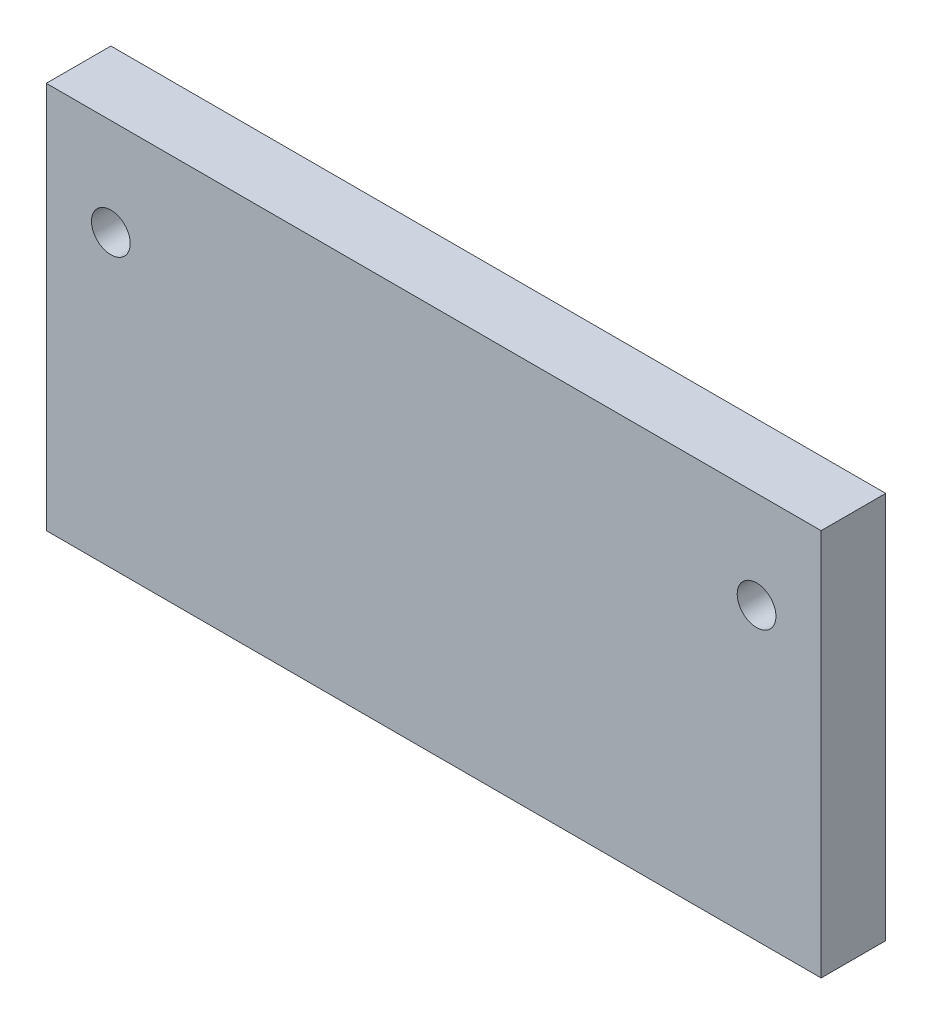
from build123d import *

# Parameters (mm, degrees)
SKETCH_2_W      = 60
SKETCH_2_H      = 30
SKETCH_2_R      = 1.5
EXTRUDE_1_DEPTH = 5


with BuildPart() as part:
    # 草图2 → 凸台-拉伸1 (new body)
    with BuildSketch(Plane(origin=(0, 0, -5.68018018), x_dir=(-1, 0, 0), z_dir=(0, 0, -1))):
        with Locations((-26.720720721, 0)):
            Rectangle(SKETCH_2_W, SKETCH_2_H)
        with Locations((-51.720720721, 7.5)):
            Circle(SKETCH_2_R, mode=Mode.SUBTRACT)
        with Locations((-1.720720721, 7.5)):
            Circle(SKETCH_2_R, mode=Mode.SUBTRACT)
    extrude(amount=EXTRUDE_1_DEPTH)


solid = part.part
